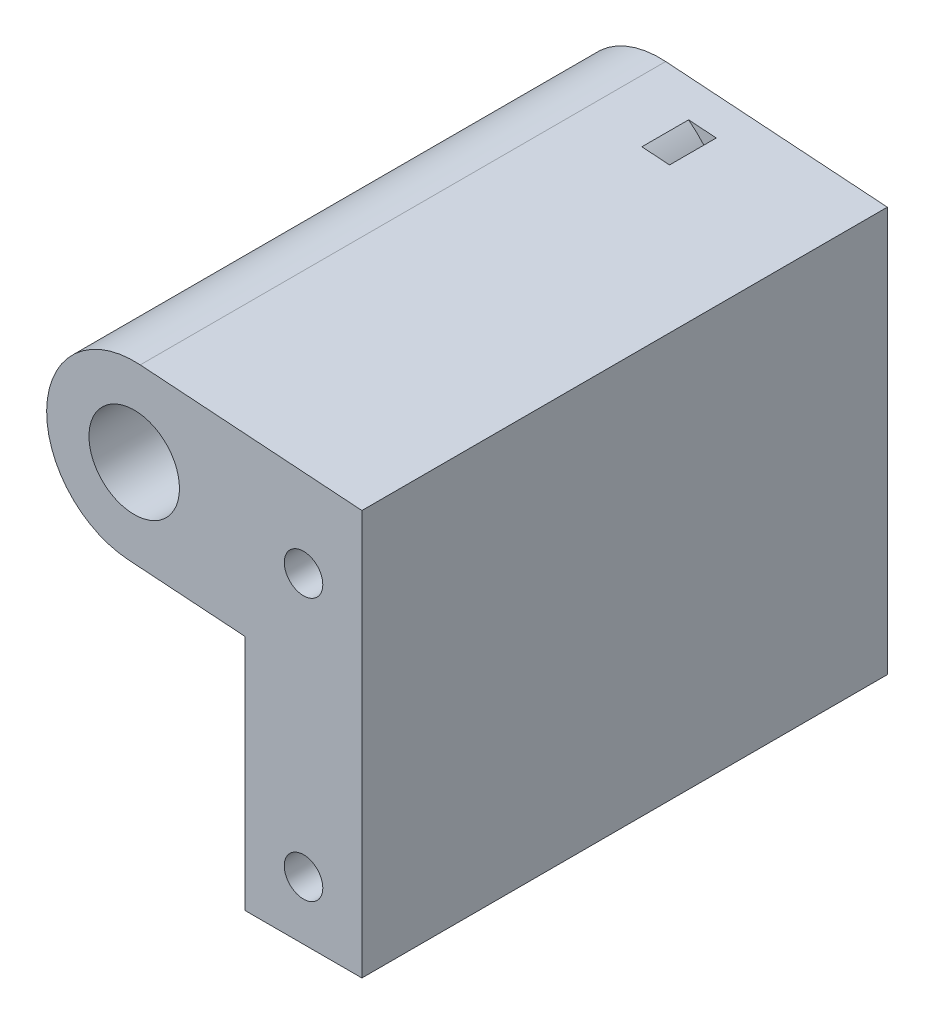
from build123d import *

# Parameters (mm, degrees)
BOSS_EXTRUDE1_DEPTH   = 45
CUT_EXTRUDE1_START    = -5
CUT_EXTRUDE1_DEPTH    = 2
M4X0_7_TAPPED_HOLE1_D = 3.3
SKETCH5_R             = 7.5
BOSS_EXTRUDE2_DEPTH   = 45
SKETCH6_R             = 3.875
CUT_EXTRUDE2_DEPTH    = 46


with BuildPart() as part:
    # Sketch1 → Boss-Extrude1 (new body)
    with BuildSketch(Plane.XY):
        with BuildLine():
            Line((-182.516015687, 162.517772537), (-172.5, 161.827012834))
            Line((-172.5, 161.827012834), (-172.5, 141.5))
            Line((-172.5, 141.5), (-162.5, 141.5))
            Line((-162.5, 141.5), (-162.5, 176.172987166))
            Line((-162.5, 176.172987166), (-181.483984313, 177.482227463))
            ThreePointArc((-181.483984313, 177.482227463), (-174.517772537, 169.483984313), (-182.516015687, 162.517772537))
        make_face()
    extrude(amount=BOSS_EXTRUDE1_DEPTH)

    # Sketch2 → Cut-Extrude1 (cut, symmetric)
    with BuildSketch(Plane(origin=(0, 0, 0), x_dir=(-1, 0, 0), z_dir=(0, 0, -1)).offset(CUT_EXTRUDE1_START)):
        with BuildLine():
            ThreePointArc((176.520836095, 177.139941379), (173.021327044, 169.380781175), (177.552867469, 162.175486453))
            ThreePointArc((177.552867469, 162.175486453), (177.834315887, 161.15284928), (176.811678714, 160.871400862))
            ThreePointArc((176.811678714, 160.871400862), (171.524881552, 169.277578038), (175.60764211, 178.329931609))
            ThreePointArc((175.60764211, 178.329931609), (176.659234217, 178.191533486), (176.520836095, 177.139941379))
        make_face()
    extrude(amount=CUT_EXTRUDE1_DEPTH, both=True, mode=Mode.SUBTRACT)

    # M4x0.7 Tapped Hole1 (through all)
    with Locations(Plane.XY.offset(45)):
        with Locations((-167.5, 169), (-167.5, 146.5)):
            Hole(M4X0_7_TAPPED_HOLE1_D / 2)

    # Sketch5 → Boss-Extrude2 (add, through all)
    with BuildSketch(Plane.XY.offset(45)):
        with Locations((-182, 170)):
            Circle(SKETCH5_R)
    extrude(amount=-BOSS_EXTRUDE2_DEPTH)

    # Sketch6 → Cut-Extrude2 (cut, through all)
    with BuildSketch(Plane.XY.offset(45)):
        with Locations((-182, 170)):
            Circle(SKETCH6_R)
    extrude(amount=-CUT_EXTRUDE2_DEPTH, mode=Mode.SUBTRACT)


solid = part.part
